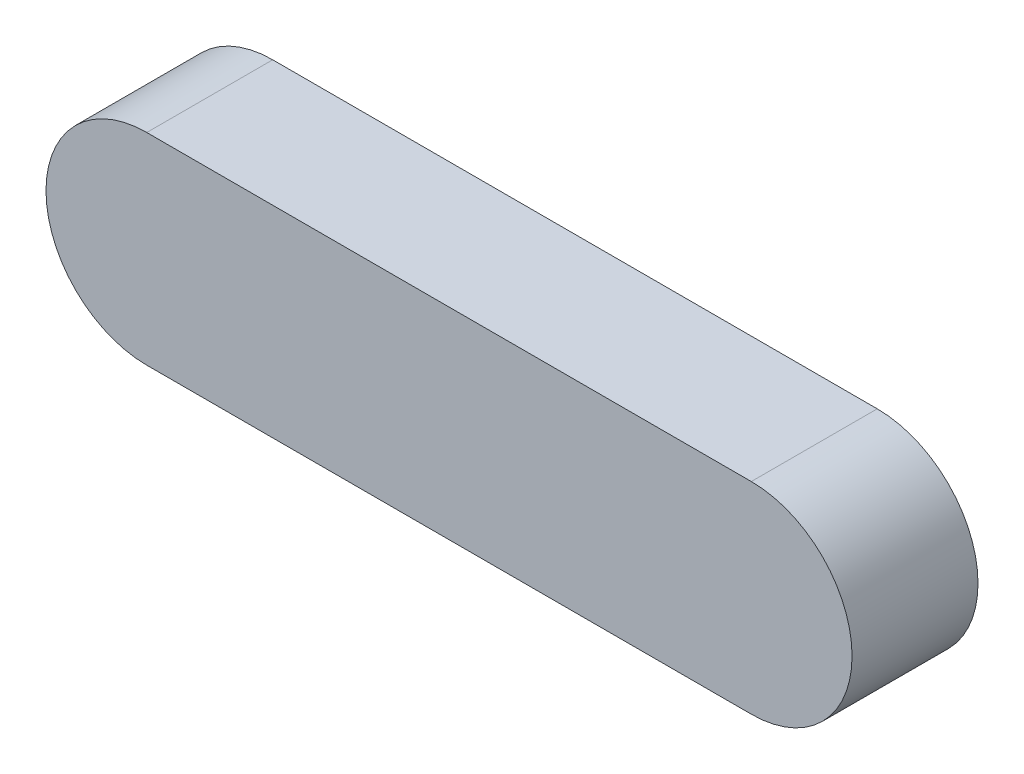
from build123d import *

# Parameters (mm, degrees)
BOSS_EXTRUDE1_DEPTH = 10


with BuildPart() as part:
    # Sketch1 → Boss-Extrude1 (new body)
    with BuildSketch(Plane.XY):
        with BuildLine():
            Line((-7.667924528, 8), (40.332075472, 8))
            ThreePointArc((40.332075472, 8), (48.332075472, 0), (40.332075472, -8))
            Line((40.332075472, -8), (-7.667924528, -8))
            ThreePointArc((-7.667924528, -8), (-15.667924528, 0), (-7.667924528, 8))
        make_face()
    extrude(amount=BOSS_EXTRUDE1_DEPTH)


solid = part.part
